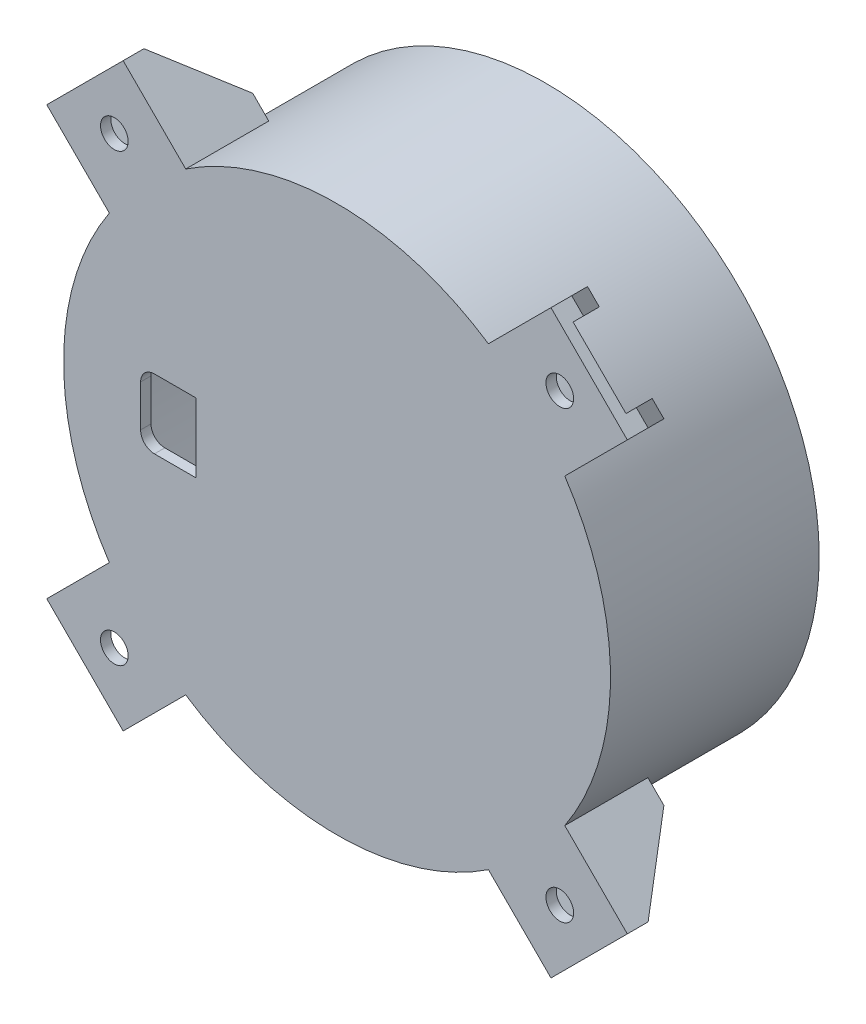
from build123d import *

# Parameters (mm, degrees)
SKETCH1_R           = 39.5
BOSS_EXTRUDE1_DEPTH = 30.15
SKETCH3_W           = 42
SKETCH3_H           = 21
CUT_EXTRUDE1_DEPTH  = 28.65
CUT_EXTRUDE2_DEPTH  = 28.65
SKETCH5_R           = 1.5
CUT_EXTRUDE3_DEPTH  = 28.65
SKETCH8_W           = 8
SKETCH8_H           = 10
CUT_EXTRUDE5_DEPTH  = 76.391291937
FILLET1_R           = 3
FILLET3_R           = 6
FILLET2_R           = 2
SKETCH12_R          = 2
BOSS_EXTRUDE3_DEPTH = 12
CUT_EXTRUDE6_REACH  = 78.373
CUT_EXTRUDE7_DEPTH  = 10.5
CIRPATTERN19_COUNT  = 4


with BuildPart() as part:
    # Sketch1 → Boss-Extrude1 (new body)
    with BuildSketch(Plane.XY):
        with Locations(Location((-9.62, 10, 0), (0, 0, 180))):
            Circle(SKETCH1_R)
    extrude(amount=BOSS_EXTRUDE1_DEPTH)

    # Sketch3 → Cut-Extrude1 (cut)
    with BuildSketch(Plane(origin=(0, 0, 0), x_dir=(-1, 0, 0), z_dir=(0, 0, -1))):
        with Locations((0, 10)):
            Rectangle(SKETCH3_W, SKETCH3_H)
    extrude(amount=-CUT_EXTRUDE1_DEPTH, mode=Mode.SUBTRACT)

    # Sketch4 → Cut-Extrude2 (cut)
    with BuildSketch(Plane(origin=(0, 0, 0), x_dir=(-1, 0, 0), z_dir=(0, 0, -1))):
        with BuildLine():
            Line((30, -1.8), (-25.55342747, -1.8))
            ThreePointArc((-25.55342747, -1.8), (46.72, 10), (-25.55342747, 21.8))
            Line((-25.55342747, 21.8), (30, 21.8))
            Line((30, 21.8), (30, -1.8))
        make_face()
    extrude(amount=-CUT_EXTRUDE2_DEPTH, mode=Mode.SUBTRACT)

    # Sketch5 → Cut-Extrude3 (cut)
    with BuildSketch(Plane(origin=(0, 0, 0), x_dir=(-1, 0, 0), z_dir=(0, 0, -1))):
        with Locations((25, 4.96)):
            Circle(SKETCH5_R)
        with Locations((25, 15.04)):
            Circle(SKETCH5_R)
        with Locations((-25, 4.96)):
            Circle(SKETCH5_R)
        with Locations((-25, 15.04)):
            Circle(SKETCH5_R)
        Polygon((30, 7), (22.813409321, 7), (21, 6), (21, 7), (21, 13), (21, 14), (22.813409321, 13), (30, 13), align=None)
    extrude(amount=-CUT_EXTRUDE3_DEPTH, mode=Mode.SUBTRACT)

    # Sketch8 → Cut-Extrude5 (cut, through all)
    with BuildSketch(Plane(origin=(0, 0, 28.65), x_dir=(-1, 0, 0), z_dir=(0, 0, -1))):
        with Locations((34, 10)):
            Rectangle(SKETCH8_W, SKETCH8_H)
    extrude(amount=-CUT_EXTRUDE5_DEPTH, mode=Mode.SUBTRACT)

    # Fillet1
    fillet1_edges = [part.edges().sort_by_distance(p)[0] for p in [
        (-30, -1.8, 14.325),
        (-30, 21.8, 14.325),
    ]]
    fillet(fillet1_edges, radius=FILLET1_R)

    # Fillet3
    fillet3_edges = [part.edges().sort_by_distance(p)[0] for p in [
        (25.55342747, 21.8, 14.325),
        (25.55342747, -1.8, 14.325),
    ]]
    fillet(fillet3_edges, radius=FILLET3_R)

    # Fillet2
    fillet2_edges = [part.edges().sort_by_distance(p)[0] for p in [
        (-30, 13, 14.325),
        (-30, 7, 14.325),
        (-22.813409321, 7, 14.325),
        (-21, 6, 14.325),
        (-21, 14, 14.325),
        (-22.813409321, 13, 14.325),
        (-38, 15, 29.4),
        (-38, 5, 29.4),
    ]]
    fillet(fillet2_edges, radius=FILLET2_R)


with BuildPart() as body_2:
    # Sketch12 → Boss-Extrude3 (new body)
    with BuildSketch(Plane.XY.offset(30.15)):
        with BuildLine():
            Line((22.915425491, -11.504559705), (32.311432124, -20.900566338))
            Line((32.311432124, -20.900566338), (21.280566338, -31.931432124))
            Line((21.280566338, -31.931432124), (11.884559705, -22.535425491))
            ThreePointArc((11.884559705, -22.535425491), (17.957164466, -17.577164466), (22.915425491, -11.504559705))
        make_face()
        with Locations((22.553358544, -22.173358544)):
            Circle(SKETCH12_R, mode=Mode.SUBTRACT)
    extrude(amount=-BOSS_EXTRUDE3_DEPTH)

    # Cut-Extrude6: up to this face of the body (flat: up to its plane)
    cut_extrude6_end = Plane(body_2.part.faces().sort_by_distance((27.613428808, -16.202563021, 24.15))[0])
    # Sketch13 → Cut-Extrude6 (cut, up to the picked face)
    with BuildSketch(Plane(origin=(-5.325432893, -5.325432893, 0), x_dir=(0, 0, 1), z_dir=(-0.7071067811865415, -0.7071067811865537, 0)), mode=Mode.PRIVATE) as cut_extrude6_sk1:
        Polygon((18.15, -37.626564953), (27.15, -37.626564953), (18.15, -28.126564953), align=None)
    cut_extrude6_tool1 = split(extrude(cut_extrude6_sk1.sketch, amount=-CUT_EXTRUDE6_REACH, mode=Mode.PRIVATE), bisect_by=cut_extrude6_end, keep=Keep.BOTH, mode=Mode.PRIVATE)
    add(cut_extrude6_tool1.solids().sort_by(Axis((19.041395, -29.692261, 21.15), (0.7071067811865415, 0.7071067811865537, 0)))[0], mode=Mode.SUBTRACT)

    # Sketch14 → Cut-Extrude7 (cut)
    with BuildSketch(Plane(origin=(0, 0, 18.15), x_dir=(-1, 0, 0), z_dir=(0, 0, -1))):
        with BuildLine():
            Line((-14.230107258, -21.486860494), (-22.977622613, -30.23437585))
            Line((-22.977622613, -30.23437585), (-30.61437585, -22.597622613))
            Line((-30.61437585, -22.597622613), (-21.866860494, -13.850107258))
            ThreePointArc((-21.866860494, -13.850107258), (-18.310717857, -17.930717857), (-14.230107258, -21.486860494))
        make_face()
    extrude(amount=-CUT_EXTRUDE7_DEPTH, mode=Mode.SUBTRACT)


with BuildPart() as cirpattern19_1:
    # CirPattern19: pattern copy
    add(body_2.part.rotate(Axis((-9.62, 10, 0), (0, 0, 1)), 1 * 360 / CIRPATTERN19_COUNT))


with BuildPart() as cirpattern19_2:
    # CirPattern19: pattern copy
    add(body_2.part.rotate(Axis((-9.62, 10, 0), (0, 0, 1)), 2 * 360 / CIRPATTERN19_COUNT))


with BuildPart() as cirpattern19_3:
    # CirPattern19: pattern copy
    add(body_2.part.rotate(Axis((-9.62, 10, 0), (0, 0, 1)), 3 * 360 / CIRPATTERN19_COUNT))


with BuildPart() as part_1:
    add(part.part)

    # Combine1: union body 2, CirPattern19_3, CirPattern19_2, CirPattern19_1
    add(body_2.part)
    add(cirpattern19_3.part)
    add(cirpattern19_2.part)
    add(cirpattern19_1.part)


solid = part_1.part
